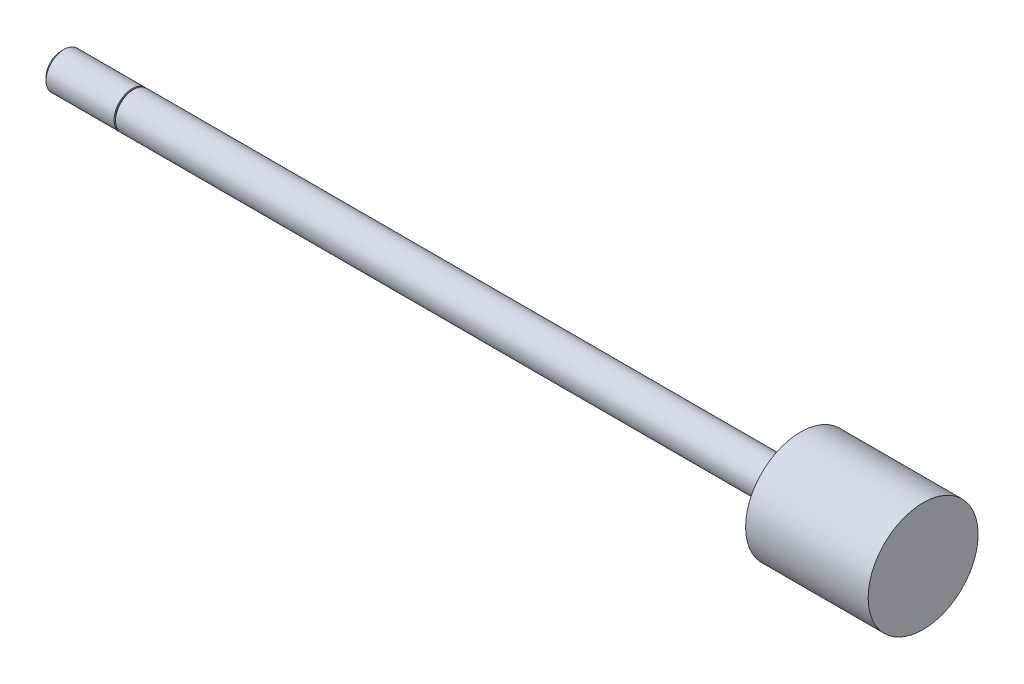
from build123d import *

# Parameters (mm, degrees)
SKETCH3_W = 0.254
SKETCH3_H = 0.508


with BuildPart() as part:
    # Sketch1 → Revolve1 (revolve)
    with BuildSketch(Plane.XY):
        Polygon((0, 0), (0, 3.175), (116.6876, 3.175), (116.6876, 9.62025), (138.1252, 9.62025), (138.1252, 0), align=None)
    revolve(axis=Axis((138.1252, 0, 0), (-1, 0, 0)))

    # Sketch2 → Revolve2 (revolve)
    with BuildSketch(Plane.XY):
        Polygon((-12.7, 0), (-12.7, 2.63398), (-12.15898, 3.175), (0, 3.175), (0, 0), align=None)
    revolve(axis=Axis((0, 0, 0), (-1, 0, 0)))

    # Sketch3 → Cut-Revolve1 (revolve, cut)
    with BuildSketch(Plane.XY):
        with Locations((-0.127, 3.175)):
            Rectangle(SKETCH3_W, SKETCH3_H)
    revolve(axis=Axis((0, 0, 0), (-1, 0, 0)), mode=Mode.SUBTRACT)


solid = part.part
